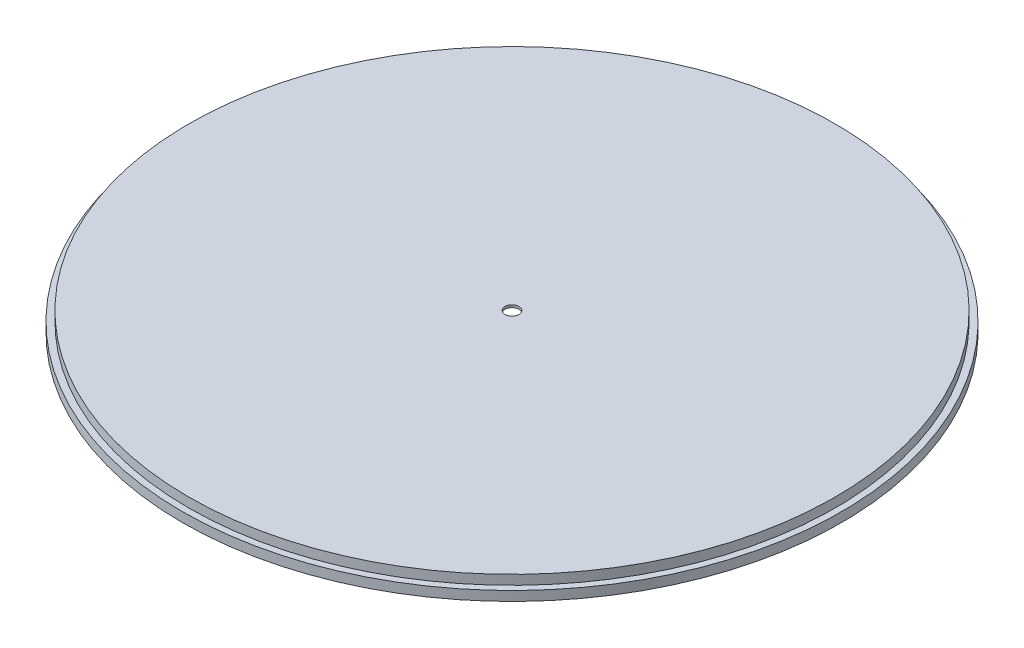
from build123d import *

# Parameters (mm, degrees)
SKETCH1_R           = 25.5
BOSS_EXTRUDE1_DEPTH = 1.5
SKETCH2_R           = 26
BOSS_EXTRUDE2_DEPTH = 0.75
SKETCH3_R           = 0.6
CUT_EXTRUDE1_DEPTH  = 1.75


with BuildPart() as part:
    # Sketch1 → Boss-Extrude1 (new body)
    with BuildSketch(Plane(origin=(0, 0, 0), x_dir=(1, 0, 0), z_dir=(0, 1, 0))):
        Circle(SKETCH1_R)
    extrude(amount=-BOSS_EXTRUDE1_DEPTH)

    # Sketch2 → Boss-Extrude2 (add)
    with BuildSketch(Plane(origin=(0, -1.5, 0), x_dir=(-1, 0, 0), z_dir=(0, -1, 0))):
        Circle(SKETCH2_R)
    extrude(amount=-BOSS_EXTRUDE2_DEPTH)

    # Sketch3 → Cut-Extrude1 (cut, through all)
    with BuildSketch(Plane(origin=(0, -0.75, 0), x_dir=(1, 0, 0), z_dir=(0, 1, 0))):
        Circle(SKETCH3_R)
    extrude(amount=-CUT_EXTRUDE1_DEPTH, mode=Mode.SUBTRACT)

    # Sketch4 → Cut-Revolve1 (revolve, cut)
    with BuildSketch(Plane.XY):
        Polygon((-4.35, -1.5), (0, -1.5), (0, 0), (-0.55, 0), (-0.55, -0.2), align=None)
    revolve(axis=Axis((0, -1.5, 0), (0, 1, 0)), mode=Mode.SUBTRACT)


solid = part.part
